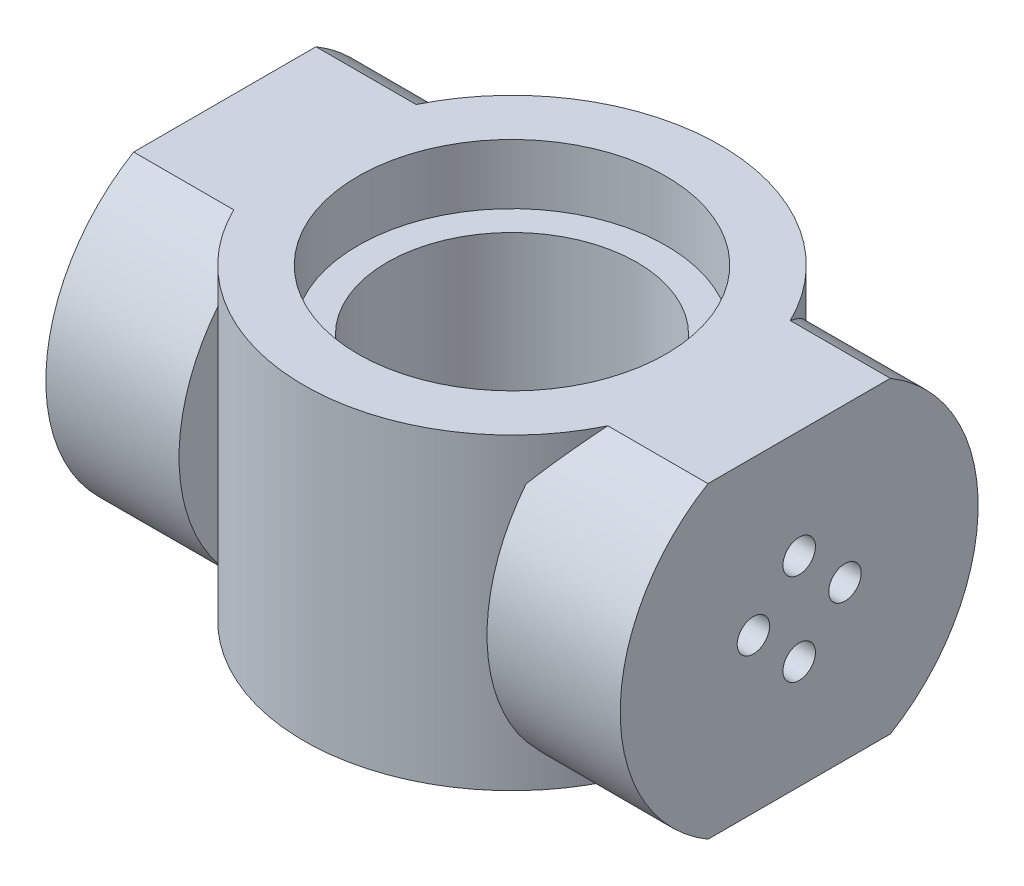
from build123d import *

# Parameters (mm, degrees)
SKIZZE1_R                            = 25
SKIZZE1_R_2                          = 18.5
AUFSATZ_LINEAR_AUSTRAGEN1_DEPTH      = 18.5
SKIZZE2_R                            = 18.5
SKIZZE2_R_2                          = 15
AUFSATZ_LINEAR_AUSTRAGEN2_DEPTH      = 11.3
SKIZZE3_R                            = 21.5
AUFSATZ_LINEAR_AUSTRAGEN3_DEPTH      = 16
SKIZZE4_R                            = 1.95
SCHNITT_LINEAR_AUSTRAGEN1_DEPTH      = 4.2
SCHNITT_LINEAR_AUSTRAGEN2_DEPTH      = 67.290769445
SCHNITT_LINEAR_AUSTRAGEN2_DEPTH_BACK = 67.290769445
SKIZZE5_OUTSIDE_W                    = 64.09
SKIZZE5_OUTSIDE_H                    = 71.09
SKIZZE5_OUTSIDE_W_2                  = 37
SKIZZE5_OUTSIDE_H_2                  = 50


with BuildPart() as part:
    # Skizze1 → Aufsatz-Linear austragen1 (new, symmetric)
    with BuildSketch(Plane(origin=(0, 0, 0), x_dir=(1, 0, 0), z_dir=(0, 1, 0))):
        Circle(SKIZZE1_R)
        Circle(SKIZZE1_R_2, mode=Mode.SUBTRACT)
    extrude(amount=AUFSATZ_LINEAR_AUSTRAGEN1_DEPTH, both=True)

    # Skizze2 → Aufsatz-Linear austragen2 (add, symmetric)
    with BuildSketch(Plane(origin=(0, 0, 0), x_dir=(1, 0, 0), z_dir=(0, 1, 0))):
        Circle(SKIZZE2_R)
        Circle(SKIZZE2_R_2, mode=Mode.SUBTRACT)
    extrude(amount=AUFSATZ_LINEAR_AUSTRAGEN2_DEPTH, both=True)

    # Skizze3 → Aufsatz-Linear austragen3 (add)
    with BuildSketch(Plane(origin=(18.5, 0, 0), x_dir=(0, 0, -1), z_dir=(1, 0, 0))):
        Circle(SKIZZE3_R)
    aufsatz_linear_austragen3 = extrude(amount=AUFSATZ_LINEAR_AUSTRAGEN3_DEPTH)

    # Skizze4 → Schnitt-Linear austragen1 (cut)
    with BuildSketch(Plane(origin=(34.5, 0, 0), x_dir=(0, 0, -1), z_dir=(1, 0, 0))):
        with Locations((-5.5, 0)):
            Circle(SKIZZE4_R)
        with Locations((0, 5.5)):
            Circle(SKIZZE4_R)
        with Locations((5.5, 0)):
            Circle(SKIZZE4_R)
        with Locations((0, -5.5)):
            Circle(SKIZZE4_R)
    schnitt_linear_austragen1 = extrude(amount=-SCHNITT_LINEAR_AUSTRAGEN1_DEPTH, mode=Mode.SUBTRACT)

    # Spiegeln1: Aufsatz-Linear austragen3, Schnitt-Linear austragen1 across plane
    add(aufsatz_linear_austragen3.mirror(Plane(origin=(0, 0, 0), x_dir=(0, 0, 1), z_dir=(1, 0, 0))))
    add(schnitt_linear_austragen1.mirror(Plane(origin=(0, 0, 0), x_dir=(0, 0, 1), z_dir=(1, 0, 0))), mode=Mode.SUBTRACT)

    # Skizze5 outside → Schnitt-Linear austragen2 (cut, two sides: drawn at the far end of the back side and taken through both)
    with BuildSketch(Plane(origin=(0, 29.28598322, 0), x_dir=(0, -1, 0), z_dir=(-1, 0, 0)).offset(-SCHNITT_LINEAR_AUSTRAGEN2_DEPTH_BACK)):
        with Locations((29.286, 0)):
            Rectangle(SKIZZE5_OUTSIDE_W, SKIZZE5_OUTSIDE_H)
        with Locations((29.28598322, 0)):
            Rectangle(SKIZZE5_OUTSIDE_W_2, SKIZZE5_OUTSIDE_H_2, mode=Mode.SUBTRACT)
    extrude(amount=SCHNITT_LINEAR_AUSTRAGEN2_DEPTH + SCHNITT_LINEAR_AUSTRAGEN2_DEPTH_BACK, mode=Mode.SUBTRACT)


solid = part.part
